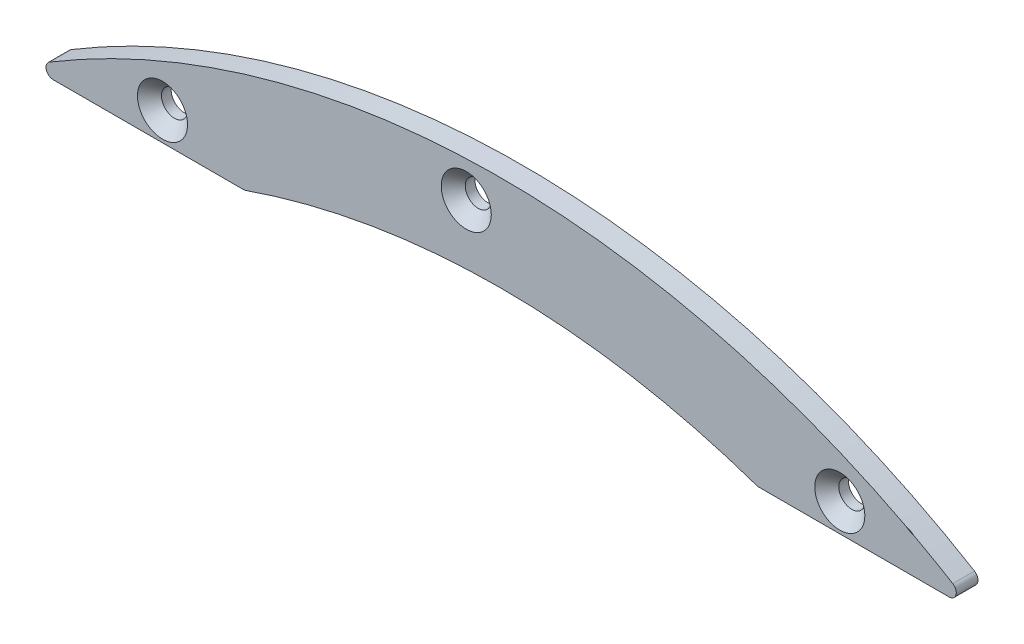
from build123d import *

# Parameters (mm, degrees)
BOSS_EXTRU_1_DEPTH                          = 3.75
FRAISAGE_POUR_VIS_T_TE_FRAIS_E_M81_AT_COUNT = 2
FRAISAGE_POUR_VIS_T_TE_FRAIS_E_M81_AT_PITCH = 131.556522493
FRAISAGE_POUR_VIS_T_TE_FRAIS_E_M81_2_COUNT  = 2
FRAISAGE_POUR_VIS_T_TE_FRAIS_E_M81_2_PITCH  = 108
FRAISAGE_POUR_VIS_T_TE_FRAIS_E_M81_3_COUNT  = 2
FRAISAGE_POUR_VIS_T_TE_FRAIS_E_M81_3_PITCH  = 158
ENL_V_MAT_EXTRU_1_DEPTH                     = 3


with BuildPart() as part:
    # Esquisse1 → Boss.-Extru.1 (new body, symmetric)
    with BuildSketch(Plane.XY):
        with BuildLine():
            Line((-154.75, 254.46002907), (-88.649878015, 254.46002907))
            ThreePointArc((-88.649878015, 254.46002907), (0, 269.46002907), (88.649878015, 254.46002907))
            Line((88.649878015, 254.46002907), (154.75, 254.46002907))
            ThreePointArc((154.75, 254.46002907), (157.158739016, 256.290718713), (156.039755176, 259.101647987))
            ThreePointArc((156.039755176, 259.101647987), (0, 302.46002907), (-156.039755176, 259.101647987))
            ThreePointArc((-156.039755176, 259.101647987), (-157.158739016, 256.290718713), (-154.75, 254.46002907))
        make_face()
    extrude(amount=BOSS_EXTRU_1_DEPTH, both=True)

    # Esquisse2 → Fraisage pour vis à tête fraisée M81 (revolve, cut)
    with BuildSketch(Plane(origin=(-12.057945749, 289.731675966, 3.75), x_dir=(0, -1, 0), z_dir=(1, 0, 0))):
        Polygon((0, 0), (0, 7.5), (4.5, 7.5), (4.5, 4.15), (8.65, 0), align=None)
    fraisage_pour_vis_t_te_frais_e_m81 = revolve(axis=Axis((-12.057945749, 289.731675966, 10.1), (0, 0, -1)), mode=Mode.SUBTRACT)

    # Fraisage pour vis à tête fraisée M81 at: Fraisage pour vis à tête fraisée M81 ×2
    with Locations(*[Vector(0.98100758, -0.1939694, 0) * (i * FRAISAGE_POUR_VIS_T_TE_FRAIS_E_M81_AT_PITCH) for i in range(1, FRAISAGE_POUR_VIS_T_TE_FRAIS_E_M81_AT_COUNT)]):
        add(fraisage_pour_vis_t_te_frais_e_m81, mode=Mode.SUBTRACT)

    # Fraisage pour vis _ t_te frais_e M81 2: Fraisage pour vis à tête fraisée M81 ×2
    with Locations(*[Vector(-0.971685688, -0.23627722, 0) * (i * FRAISAGE_POUR_VIS_T_TE_FRAIS_E_M81_2_PITCH) for i in range(1, FRAISAGE_POUR_VIS_T_TE_FRAIS_E_M81_2_COUNT)]):
        add(fraisage_pour_vis_t_te_frais_e_m81, mode=Mode.SUBTRACT)

    # Fraisage pour vis _ t_te frais_e M81 3: Fraisage pour vis à tête fraisée M81 ×2
    with Locations(*[Vector(0.99561991, -0.09349329, 0) * (i * FRAISAGE_POUR_VIS_T_TE_FRAIS_E_M81_3_PITCH) for i in range(1, FRAISAGE_POUR_VIS_T_TE_FRAIS_E_M81_3_COUNT)]):
        add(fraisage_pour_vis_t_te_frais_e_m81, mode=Mode.SUBTRACT)

    # Esquisse4 → Enlèv. mat.-Extru.1 (cut)
    with BuildSketch(Plane(origin=(0, 0, -3.75), x_dir=(-1, 0, 0), z_dir=(0, 0, -1))):
        with BuildLine():
            Line((25.420420264, 281.748761245), (36.734128763, 293.062469744))
            ThreePointArc((36.734128763, 293.062469744), (40.269662669, 293.062469744), (40.269662669, 289.526935838))
            Line((40.269662669, 289.526935838), (44.512303356, 285.284295151))
            ThreePointArc((44.512303356, 285.284295151), (48.047837262, 285.284295151), (48.047837262, 281.748761245))
            Line((48.047837262, 281.748761245), (36.734128763, 270.435052746))
            ThreePointArc((36.734128763, 270.435052746), (33.198594857, 270.435052746), (33.198594857, 273.970586652))
            Line((33.198594857, 273.970586652), (28.95595417, 278.213227339))
            ThreePointArc((28.95595417, 278.213227339), (25.420420264, 278.213227339), (25.420420264, 281.748761245))
        make_face()
    extrude(amount=-ENL_V_MAT_EXTRU_1_DEPTH, mode=Mode.SUBTRACT)


solid = part.part
